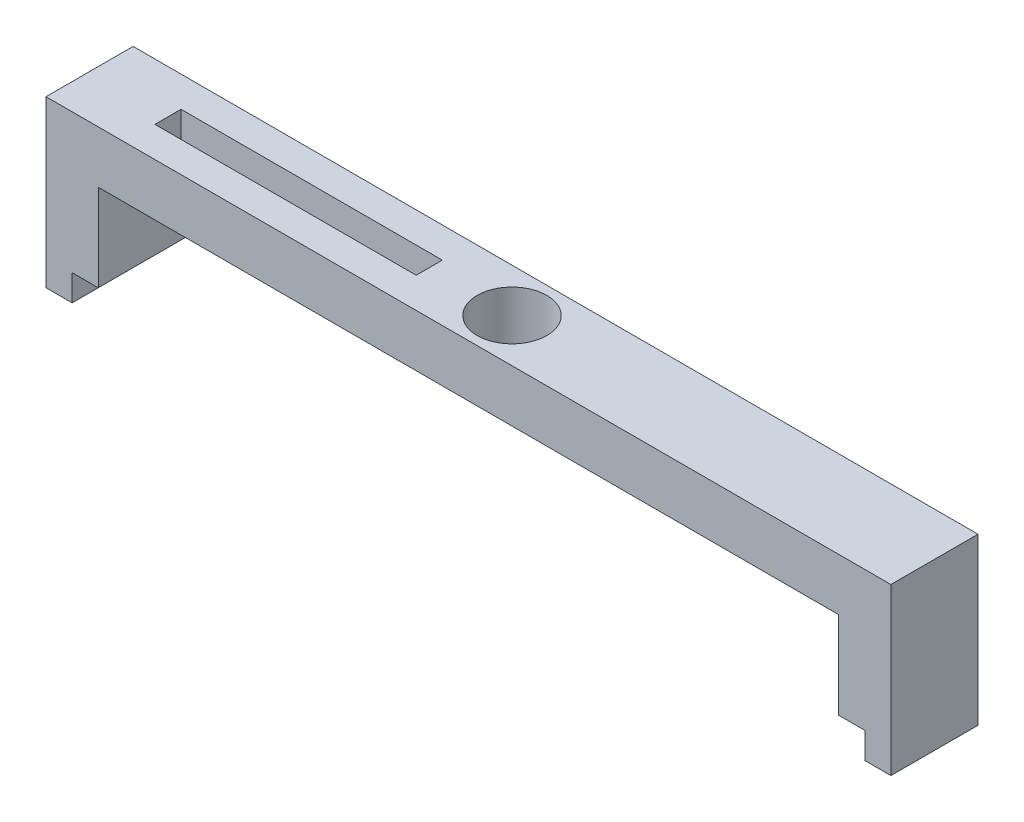
from build123d import *

# Parameters (mm, degrees)
SALIENTE_EXTRUIR1_DEPTH = 10
CROQUIS4_R              = 4
CROQUIS4_W              = 30
CROQUIS4_H              = 3
CORTAR_EXTRUIR1_DEPTH   = 10


with BuildPart() as part:
    # Croquis2 → Saliente-Extruir1 (new body)
    with BuildSketch(Plane.XY):
        Polygon((-43.412140575, 0), (35.587859425, 0), (38.587859425, 0), (38.587859425, -10), (41.587859425, -10), (41.587859425, -13), (44.587859425, -13), (44.587859425, 6), (-52.412140575, 6), (-52.412140575, -13), (-49.412140575, -13), (-49.412140575, -10), (-46.412140575, -10), (-46.412140575, 0), align=None)
    extrude(amount=SALIENTE_EXTRUIR1_DEPTH)

    # Croquis4 → Cortar-Extruir1 (cut)
    with BuildSketch(Plane(origin=(0, 6, 0), x_dir=(1, 0, 0), z_dir=(0, 1, 0))):
        with Locations((-3.912140575, -5)):
            Circle(CROQUIS4_R)
        with Locations((-28.412140575, -5)):
            Rectangle(CROQUIS4_W, CROQUIS4_H)
    extrude(amount=-CORTAR_EXTRUIR1_DEPTH, mode=Mode.SUBTRACT)


solid = part.part
